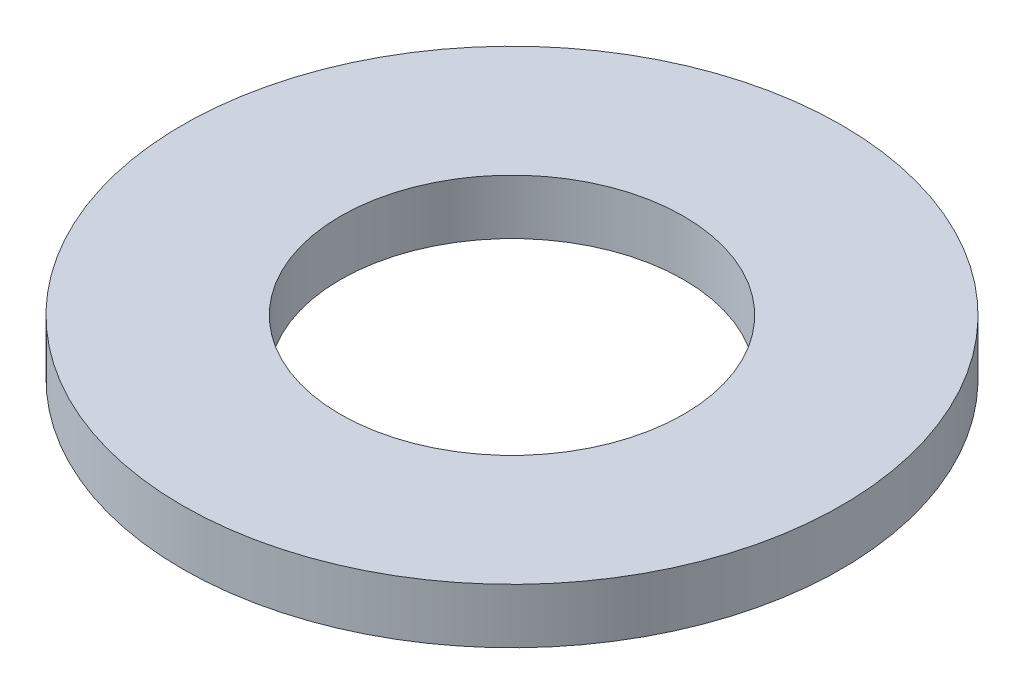
from build123d import *

# Parameters (mm, degrees)
SKETCH1_R           = 6
SKETCH1_R_2         = 3.125
BOSS_EXTRUDE1_DEPTH = 0.5


with BuildPart() as part:
    # Sketch1 → Boss-Extrude1 (new body, symmetric)
    with BuildSketch(Plane(origin=(0, 0, 0), x_dir=(1, 0, 0), z_dir=(0, 1, 0))):
        Circle(SKETCH1_R)
        Circle(SKETCH1_R_2, mode=Mode.SUBTRACT)
    extrude(amount=BOSS_EXTRUDE1_DEPTH, both=True)


solid = part.part
